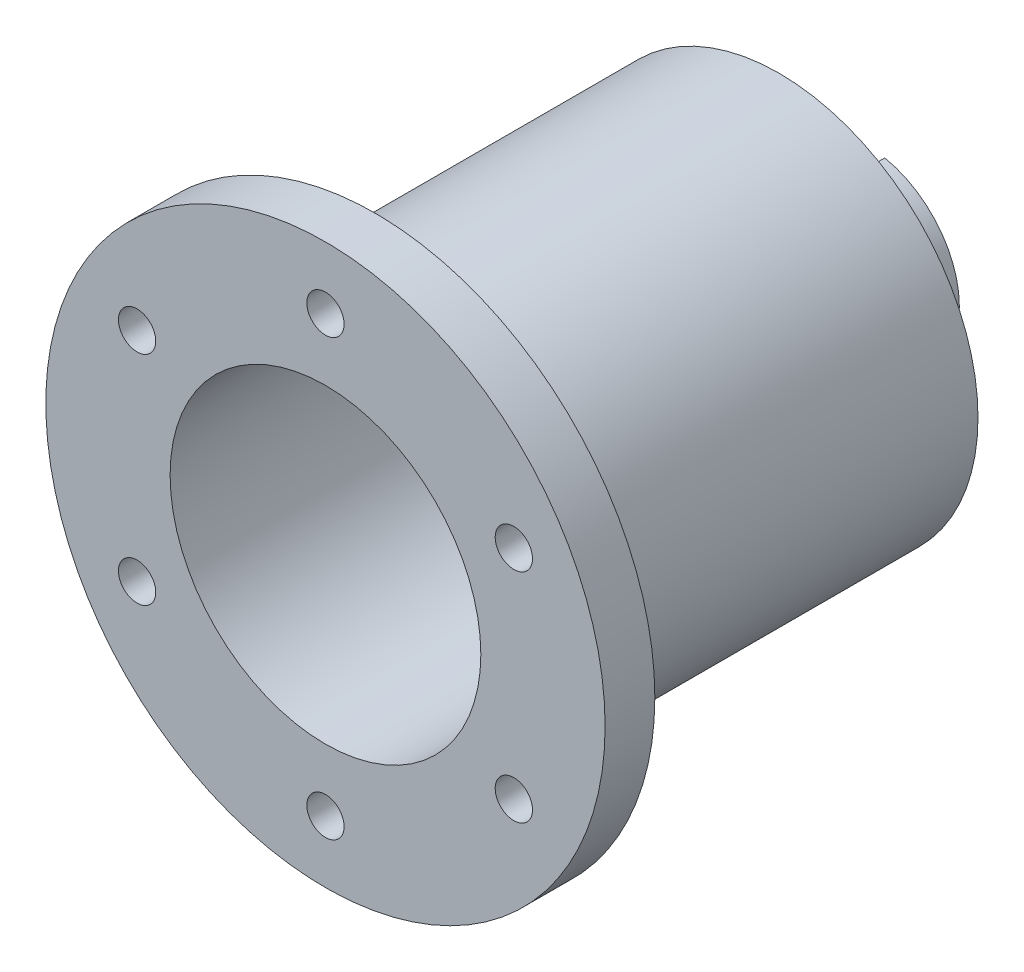
from build123d import *

# Parameters (mm, degrees)
SZKIC1_R                        = 45
SZKIC1_R_2                      = 3
DODANIE_WYCI_GNI_CIE1_DEPTH     = 8
SZKIC2_R                        = 32
DODANIE_WYCI_GNI_CIE2_DEPTH     = 65
SZKIC3_R                        = 15
DODANIE_WYCI_GNI_CIE3_DEPTH     = 14
SZKIC4_R                        = 10
WYTNIJ_WYCI_GNI_CIE1_DEPTH      = 96
SZKIC5_R                        = 25
WYTNIJ_WYCI_GNI_CIE2_DEPTH      = 65
WYTNIJ_WYCI_GNI_CIE3_DEPTH      = 19
WYTNIJ_WYCI_GNI_CIE3_DEPTH_BACK = 19


with BuildPart() as part:
    # Szkic1 → Dodanie-wyciągnięcie1 (new body)
    with BuildSketch(Plane.XY):
        Circle(SZKIC1_R)
        with Locations((0, 35)):
            Circle(SZKIC1_R_2, mode=Mode.SUBTRACT)
        with Locations((-30.310889132, 17.5)):
            Circle(SZKIC1_R_2, mode=Mode.SUBTRACT)
        with Locations((30.310889132, -17.5)):
            Circle(SZKIC1_R_2, mode=Mode.SUBTRACT)
        with Locations((30.310889132, 17.5)):
            Circle(SZKIC1_R_2, mode=Mode.SUBTRACT)
        with Locations((-30.310889132, -17.5)):
            Circle(SZKIC1_R_2, mode=Mode.SUBTRACT)
        with Locations((0, -35)):
            Circle(SZKIC1_R_2, mode=Mode.SUBTRACT)
    extrude(amount=DODANIE_WYCI_GNI_CIE1_DEPTH)

    # Szkic2 → Dodanie-wyciągnięcie2 (add)
    with BuildSketch(Plane(origin=(0, 0, 0), x_dir=(-1, 0, 0), z_dir=(0, 0, -1))):
        Circle(SZKIC2_R)
    extrude(amount=DODANIE_WYCI_GNI_CIE2_DEPTH)

    # Szkic3 → Dodanie-wyciągnięcie3 (add)
    with BuildSketch(Plane(origin=(0, 0, -65), x_dir=(-1, 0, 0), z_dir=(0, 0, -1))):
        Circle(SZKIC3_R)
    extrude(amount=DODANIE_WYCI_GNI_CIE3_DEPTH)

    # Szkic4 → Wytnij-wyciągnięcie1 (cut)
    with BuildSketch(Plane(origin=(0, 0, -79), x_dir=(-1, 0, 0), z_dir=(0, 0, -1))):
        Circle(SZKIC4_R)
    extrude(amount=-WYTNIJ_WYCI_GNI_CIE1_DEPTH, mode=Mode.SUBTRACT)

    # Szkic5 → Wytnij-wyciągnięcie2 (cut)
    with BuildSketch(Plane.XY.offset(8)):
        Circle(SZKIC5_R)
    extrude(amount=-WYTNIJ_WYCI_GNI_CIE2_DEPTH, mode=Mode.SUBTRACT)

    # Szkic6 → Wytnij-wyciągnięcie3 (cut, two sides: drawn at the far end of the back side and taken through both)
    with BuildSketch(Plane(origin=(0, 0, 0), x_dir=(1, 0, 0), z_dir=(0, 1, 0)).offset(-WYTNIJ_WYCI_GNI_CIE3_DEPTH_BACK)):
        with BuildLine():
            Line((-3, 85.590042605), (3, 85.590042605))
            Line((3, 85.590042605), (3, 68))
            ThreePointArc((3, 68), (0, 65), (-3, 68))
            Line((-3, 68), (-3, 85.590042605))
        make_face()
    extrude(amount=WYTNIJ_WYCI_GNI_CIE3_DEPTH + WYTNIJ_WYCI_GNI_CIE3_DEPTH_BACK, mode=Mode.SUBTRACT)


solid = part.part
